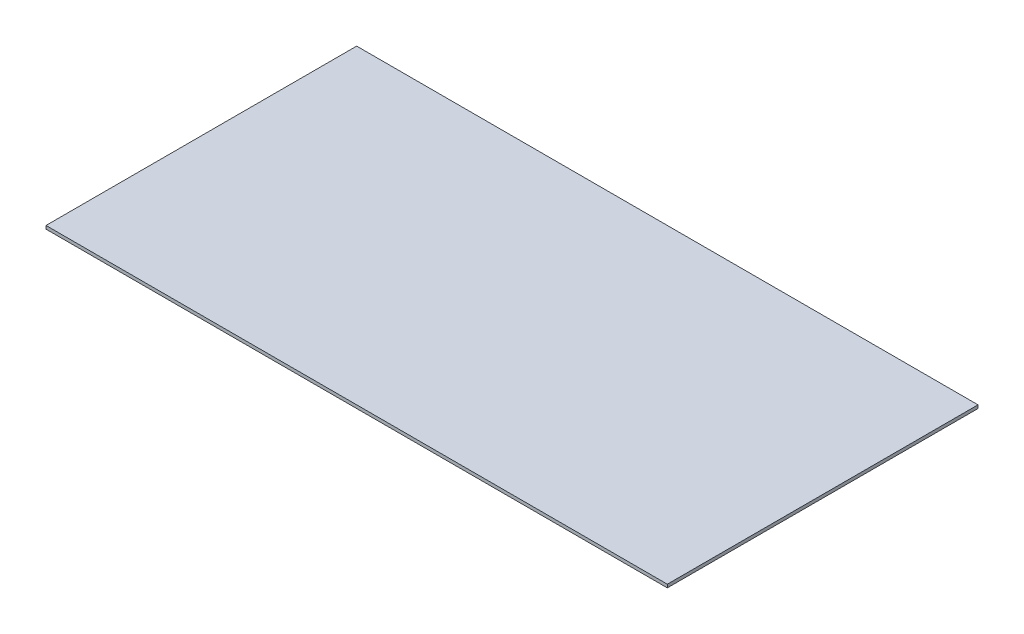
from build123d import *

# Parameters (mm, degrees)
SKETCH1_W           = 2438.4
SKETCH1_H           = 1219.2
BOSS_EXTRUDE1_DEPTH = 12.7


with BuildPart() as part:
    # Sketch1 → Boss-Extrude1 (new body)
    with BuildSketch(Plane(origin=(0, 0, 0), x_dir=(1, 0, 0), z_dir=(0, 1, 0))):
        with Locations((1219.2, 609.6)):
            Rectangle(SKETCH1_W, SKETCH1_H)
    extrude(amount=BOSS_EXTRUDE1_DEPTH)


solid = part.part
